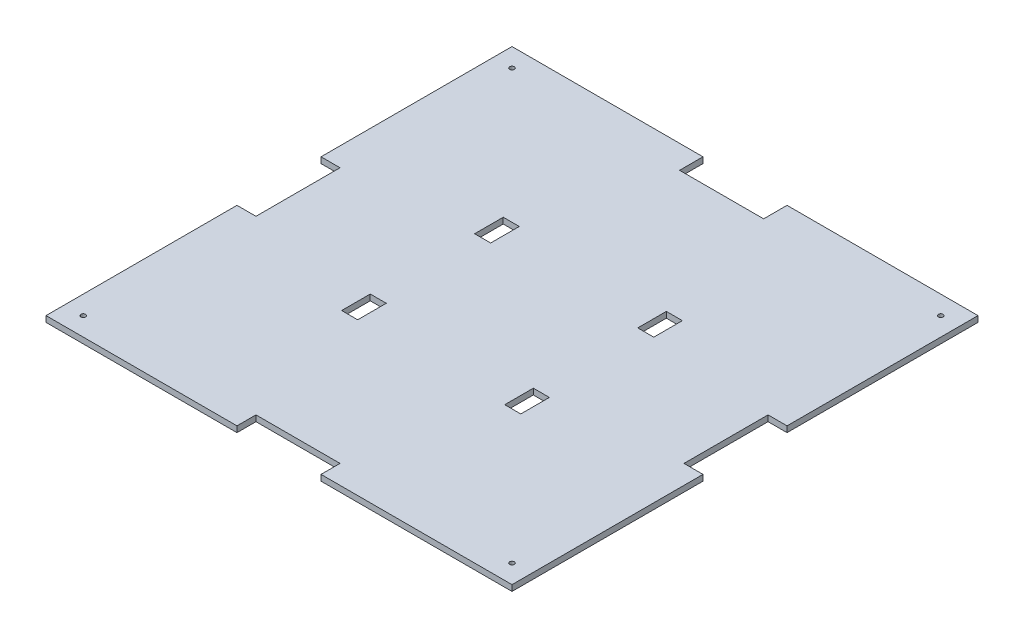
from build123d import *

# Parameters (mm, degrees)
SKETCH2_W          = 250
SKETCH2_H          = 250
BASE_DEPTH         = 3.175
SKETCH3_W          = 8.6
SKETCH3_H          = 15.35
HOLES_DEPTH        = 10
SKETCH4_W          = 45.1
SKETCH4_H          = 25.1
SKETCH4_W_2        = 20.378913316
SKETCH4_H_2        = 45.1
SKETCH4_H_3        = 20.378913316
JIGSAW_DEPTH       = 10
STANDOFF_HOLES_D   = 2.5
STANDOFF_HOLES_2_D = 2.5


with BuildPart() as part:
    # Sketch2 → Base (new body)
    with BuildSketch(Plane(origin=(0, 0, 0), x_dir=(1, 0, 0), z_dir=(0, 1, 0))):
        Rectangle(SKETCH2_W, SKETCH2_H)
    extrude(amount=BASE_DEPTH)

    # Sketch3 → Holes (cut)
    with BuildSketch(Plane(origin=(0, 3.175, 0), x_dir=(1, 0, 0), z_dir=(0, 1, 0))):
        with Locations((-43.75, 35.675)):
            Rectangle(SKETCH3_W, SKETCH3_H)
        with Locations((-43.75, -35.675)):
            Rectangle(SKETCH3_W, SKETCH3_H)
        with Locations((43.75, -35.675)):
            Rectangle(SKETCH3_W, SKETCH3_H)
        with Locations((43.75, 35.675)):
            Rectangle(SKETCH3_W, SKETCH3_H)
    extrude(amount=-HOLES_DEPTH, mode=Mode.SUBTRACT)

    # Sketch4 → Jigsaw (cut)
    with BuildSketch(Plane(origin=(0, 3.175, 0), x_dir=(1, 0, 0), z_dir=(0, 1, 0))):
        with Locations((0, 125)):
            Rectangle(SKETCH4_W, SKETCH4_H)
        with Locations((-125, 0)):
            Rectangle(SKETCH4_W_2, SKETCH4_H_2)
        with Locations((125, 0)):
            Rectangle(SKETCH4_W_2, SKETCH4_H_2)
        with Locations((0, -125)):
            Rectangle(SKETCH4_W, SKETCH4_H_3)
    extrude(amount=-JIGSAW_DEPTH, mode=Mode.SUBTRACT)

    # Standoff Holes (through all)
    with Locations(Plane(origin=(0, 3.175, 0), x_dir=(1, 0, 0), z_dir=(0, 1, 0))):
        with Locations((-115, 115)):
            Hole(STANDOFF_HOLES_D / 2)

    # Standoff Holes 2 (through all)
    with Locations(Plane(origin=(0, 3.175, 0), x_dir=(1, 0, 0), z_dir=(0, 1, 0))):
        with Locations((115, 115), (115, -115), (-115, -115)):
            Hole(STANDOFF_HOLES_2_D / 2)


solid = part.part
